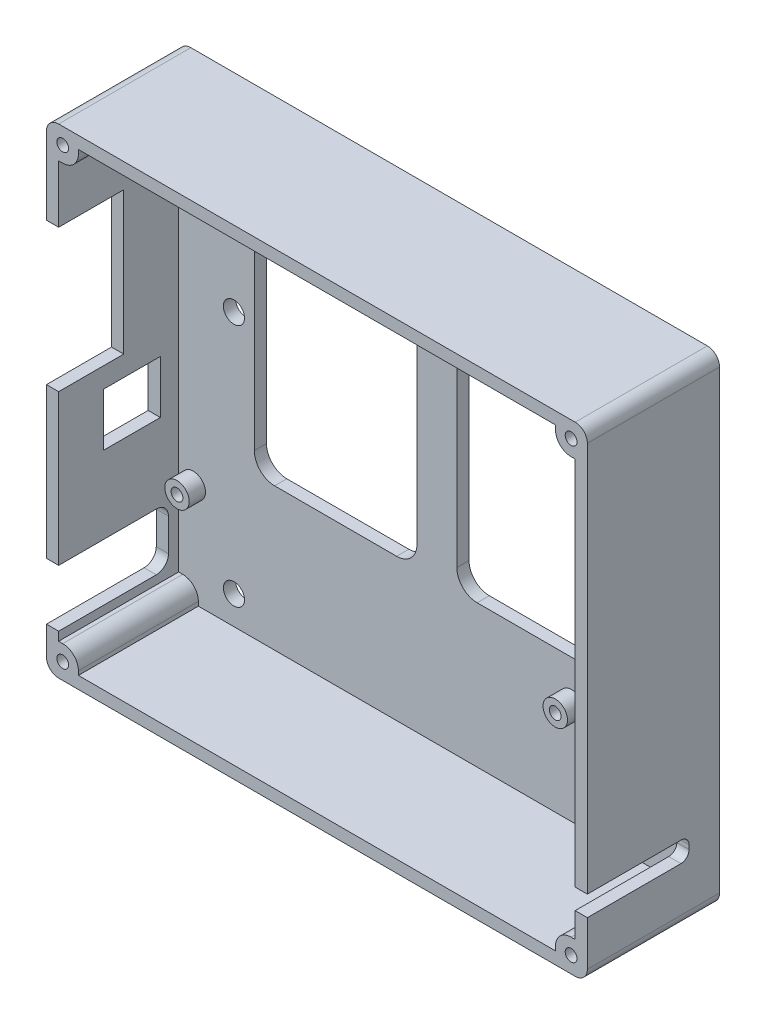
from build123d import *

# Parameters (mm, degrees)
SKETCH1_R           = 1.45
SKETCH1_R_2         = 2.6
BOSS_EXTRUDE1_DEPTH = 3
SKETCH1_3_R         = 1.45
BOSS_EXTRUDE2_DEPTH = 29.5
SKETCH1_4_R         = 3
SKETCH1_4_R_2       = 1.45
BOSS_EXTRUDE3_DEPTH = 4
SKETCH5_W           = 14
SKETCH5_H           = 13
SKETCH5_W_2         = 16
SKETCH5_H_2         = 35
CUT_EXTRUDE2_DEPTH  = 3
CUT_EXTRUDE3_REACH  = 150.46


with BuildPart() as part:
    # Sketch1 → Boss-Extrude1 (new body)
    with BuildSketch(Plane.XY):
        with BuildLine():
            Line((-63.5, -59), (63.5, -59))
            ThreePointArc((63.5, -59), (65.621320344, -58.121320344), (66.5, -56))
            Line((66.5, -56), (66.5, 56))
            ThreePointArc((66.5, 56), (65.621320344, 58.121320344), (63.5, 59))
            Line((63.5, 59), (-63.5, 59))
            ThreePointArc((-63.5, 59), (-65.621320344, 58.121320344), (-66.5, 56))
            Line((-66.5, 56), (-66.5, -56))
            ThreePointArc((-66.5, -56), (-65.621320344, -58.121320344), (-63.5, -59))
        make_face()
        with Locations((-59.9, 40.875)):
            Circle(SKETCH1_R, mode=Mode.SUBTRACT)
        with Locations((33.1, 40.875)):
            Circle(SKETCH1_R, mode=Mode.SUBTRACT)
        with Locations((33.1, -30.875)):
            Circle(SKETCH1_R, mode=Mode.SUBTRACT)
        with Locations((-59.9, -30.875)):
            Circle(SKETCH1_R, mode=Mode.SUBTRACT)
        with Locations((-49.9, 11)):
            Circle(SKETCH1_R_2, mode=Mode.SUBTRACT)
        with Locations((51.5, 11)):
            Circle(SKETCH1_R_2, mode=Mode.SUBTRACT)
        with Locations((-49.9, -49)):
            Circle(SKETCH1_R_2, mode=Mode.SUBTRACT)
        with Locations((51.5, -49)):
            Circle(SKETCH1_R_2, mode=Mode.SUBTRACT)
        with BuildLine():
            Line((44.9, 26), (44.9, -16))
            ThreePointArc((44.9, -16), (43.435533906, -19.535533906), (39.9, -21))
            Line((39.9, -21), (9.9, -21))
            ThreePointArc((9.9, -21), (6.364466094, -19.535533906), (4.9, -16))
            Line((4.9, -16), (4.9, 26))
            ThreePointArc((4.9, 26), (6.364466094, 29.535533906), (9.9, 31))
            Line((9.9, 31), (39.9, 31))
            ThreePointArc((39.9, 31), (43.435533906, 29.535533906), (44.9, 26))
        make_face(mode=Mode.SUBTRACT)
        with BuildLine():
            Line((-39.9, 31), (-9.9, 31))
            ThreePointArc((-9.9, 31), (-6.364466094, 29.535533906), (-4.9, 26))
            Line((-4.9, 26), (-4.9, -16))
            ThreePointArc((-4.9, -16), (-6.364466094, -19.535533906), (-9.9, -21))
            Line((-9.9, -21), (-39.9, -21))
            ThreePointArc((-39.9, -21), (-43.435533906, -19.535533906), (-44.9, -16))
            Line((-44.9, -16), (-44.9, 26))
            ThreePointArc((-44.9, 26), (-43.435533906, 29.535533906), (-39.9, 31))
        make_face(mode=Mode.SUBTRACT)
    extrude(amount=-BOSS_EXTRUDE1_DEPTH)

    # Sketch1_3 → Boss-Extrude2 (add)
    with BuildSketch(Plane.XY):
        with BuildLine():
            ThreePointArc((-66.5, 56), (-65.621320344, 58.121320344), (-63.5, 59))
            Line((-63.5, 59), (63.5, 59))
            ThreePointArc((63.5, 59), (65.621320344, 58.121320344), (66.5, 56))
            Line((66.5, 56), (66.5, -56))
            ThreePointArc((66.5, -56), (65.621320344, -58.121320344), (63.5, -59))
            Line((63.5, -59), (-63.5, -59))
            ThreePointArc((-63.5, -59), (-65.621320344, -58.121320344), (-66.5, -56))
            Line((-66.5, -56), (-66.5, 56))
        make_face()
        with Locations(Location((62.5, 55, 0), (0, 0, 180))):
            Circle(SKETCH1_3_R, mode=Mode.SUBTRACT)
        with Locations((-62.5, 55)):
            Circle(SKETCH1_3_R, mode=Mode.SUBTRACT)
        with Locations((62.5, -55)):
            Circle(SKETCH1_3_R, mode=Mode.SUBTRACT)
        with Locations(Location((-62.5, -55, 0), (0, 0, 180))):
            Circle(SKETCH1_3_R, mode=Mode.SUBTRACT)
        with BuildLine():
            ThreePointArc((-62.5, -51.15), (-59.777638892, -52.277638892), (-58.65, -55))
            Line((-58.65, -55), (-58.65, -56))
            Line((-58.65, -56), (58.65, -56))
            Line((58.65, -56), (58.65, -55))
            ThreePointArc((58.65, -55), (59.777638892, -52.277638892), (62.5, -51.15))
            Line((62.5, -51.15), (63.5, -51.15))
            Line((63.5, -51.15), (63.5, 51.15))
            Line((63.5, 51.15), (62.5, 51.15))
            ThreePointArc((62.5, 51.15), (59.777638892, 52.277638892), (58.65, 55))
            Line((58.65, 55), (58.65, 56))
            Line((58.65, 56), (-58.65, 56))
            Line((-58.65, 56), (-58.65, 55))
            ThreePointArc((-58.65, 55), (-59.777638892, 52.277638892), (-62.5, 51.15))
            Line((-62.5, 51.15), (-63.5, 51.15))
            Line((-63.5, 51.15), (-63.5, -51.15))
            Line((-63.5, -51.15), (-62.5, -51.15))
        make_face(mode=Mode.SUBTRACT)
    extrude(amount=BOSS_EXTRUDE2_DEPTH)

    # Sketch1_4 → Boss-Extrude3 (add)
    with BuildSketch(Plane.XY):
        with Locations(Location((-59.9, 40.875, 0), (0, 0, 180))):
            Circle(SKETCH1_4_R)
        with Locations((-59.9, 40.875)):
            Circle(SKETCH1_4_R_2, mode=Mode.SUBTRACT)
        with Locations(Location((33.1, 40.875, 0), (0, 0, 180))):
            Circle(SKETCH1_4_R)
        with Locations((33.1, 40.875)):
            Circle(SKETCH1_4_R_2, mode=Mode.SUBTRACT)
        with Locations(Location((33.1, -30.875, 0), (0, 0, 180))):
            Circle(SKETCH1_4_R)
        with Locations((33.1, -30.875)):
            Circle(SKETCH1_4_R_2, mode=Mode.SUBTRACT)
        with Locations(Location((-59.9, -30.875, 0), (0, 0, 180))):
            Circle(SKETCH1_4_R)
        with Locations((-59.9, -30.875)):
            Circle(SKETCH1_4_R_2, mode=Mode.SUBTRACT)
    extrude(amount=BOSS_EXTRUDE3_DEPTH)

    # Sketch5 → Cut-Extrude2 (cut)
    with BuildSketch(Plane.ZY.offset(66.5)):
        with Locations((11.5, -9.5)):
            Rectangle(SKETCH5_W, SKETCH5_H)
        with BuildLine():
            Line((29.5, -35), (5.5, -35))
            ThreePointArc((5.5, -35), (3.378679656, -35.878679656), (2.5, -38))
            Line((2.5, -38), (2.5, -46))
            ThreePointArc((2.5, -46), (3.378679656, -48.121320344), (5.5, -49))
            Line((5.5, -49), (29.5, -49))
            Line((29.5, -49), (29.5, -35))
        make_face()
        with Locations((21.5, 19.5)):
            Rectangle(SKETCH5_W_2, SKETCH5_H_2)
    extrude(amount=-CUT_EXTRUDE2_DEPTH, mode=Mode.SUBTRACT)

    # Sketch6 → Cut-Extrude3 (cut, up to next)
    with BuildSketch(Plane(origin=(66.5, 0, 0), x_dir=(0, 0, -1), z_dir=(1, 0, 0)), mode=Mode.PRIVATE) as cut_extrude3_sk1:
        with BuildLine():
            Line((-6.5, -45), (-29.5, -45))
            Line((-29.5, -45), (-29.5, -40))
            Line((-29.5, -40), (-6.5, -40))
            ThreePointArc((-6.5, -40), (-5.085786438, -40.585786438), (-4.5, -42))
            Line((-4.5, -42), (-4.5, -43))
            ThreePointArc((-4.5, -43), (-5.085786438, -44.414213562), (-6.5, -45))
        make_face()
    cut_extrude3_tool1 = extrude(cut_extrude3_sk1.sketch, amount=-CUT_EXTRUDE3_REACH, mode=Mode.PRIVATE) & part.part
    add(cut_extrude3_tool1.solids().sort_by_distance((66.5, -42.5, 17.167851))[0], mode=Mode.SUBTRACT)


solid = part.part
